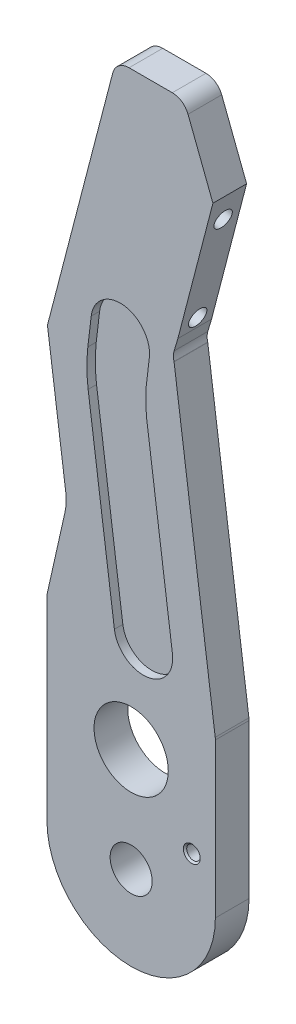
from build123d import *

# Parameters (mm, degrees)
SKETCH1_R                         = 7.9375
SKETCH1_R_2                       = 13.9954
BOSS_EXTRUDE1_DEPTH               = 12.7
FILLET3_R                         = 19.05
FILLET1_R                         = 6.35
F_10_CLEARANCE_HOLE2_D            = 5.1054
F_10_CLEARANCE_HOLE2_CSINK_D      = 6.3754
F_10_CLEARANCE_HOLE2_CSINK_ANGLE  = 90
CUT_EXTRUDE1_DEPTH                = 1
CUT_EXTRUDE1_DEPTH_BACK           = 13.7
FILLET2_R                         = 6.35
CUT_EXTRUDE3_DEPTH                = 1
CUT_EXTRUDE3_DEPTH_BACK           = 13.7
F_1_4_CLEARANCE_HOLE1_D           = 6.7564
F_1_4_CLEARANCE_HOLE1_CSINK_D     = 8.0264
F_1_4_CLEARANCE_HOLE1_CSINK_ANGLE = 90
CUT_EXTRUDE4_DEPTH                = 3.175
CUT_EXTRUDE5_DEPTH                = 3.175


with BuildPart() as part:
    # Sketch1 → Boss-Extrude1 (new body)
    with BuildSketch(Plane.XY):
        with BuildLine():
            Line((-24.200430201, 107.448474159), (-31.75, 73.770562428))
            Line((-31.75, 73.770562428), (-31.75, 0))
            ThreePointArc((-31.75, 0), (0, -31.75), (31.75, 0))
            Line((31.75, 0), (31.75, 116.627004246))
            Line((31.75, 116.627004246), (15.676297005, 175.624413942))
            Line((15.676297005, 175.624413942), (31.947601555, 229.990483385))
            Line((31.947601555, 229.990483385), (19.875208624, 261.32607122))
            Line((19.875208624, 261.32607122), (-5.524791376, 261.32607122))
            Line((-5.524791376, 261.32607122), (-32.716068836, 170.47392878))
            Line((-32.716068836, 170.47392878), (-24.200430201, 107.448474159))
        make_face()
        Circle(SKETCH1_R, mode=Mode.SUBTRACT)
        with Locations((0, 39.116)):
            Circle(SKETCH1_R_2, mode=Mode.SUBTRACT)
    extrude(amount=BOSS_EXTRUDE1_DEPTH)

    # Fillet3
    fillet3_edges = [part.edges().sort_by_distance(p)[0] for p in [
        (-24.200430201, 107.448474159, 6.35),
    ]]
    fillet(fillet3_edges, radius=FILLET3_R)

    # Fillet1
    fillet1_edges = [part.edges().sort_by_distance(p)[0] for p in [
        (-32.716068836, 170.47392878, 6.35),
        (-5.524791376, 261.32607122, 6.35),
        (19.875208624, 261.32607122, 6.35),
        (31.947601555, 229.990483385, 6.35),
        (15.676297005, 175.624413942, 6.35),
        (31.75, 116.627004246, 6.35),
        (-31.75, 73.770562428, 6.35),
    ]]
    fillet(fillet1_edges, radius=FILLET1_R)

    # #10 Clearance Hole2 (through all)
    with Locations(Plane.XY.offset(12.7)):
        with Locations((22.86, 16.52905)):
            CounterSinkHole(F_10_CLEARANCE_HOLE2_D / 2, F_10_CLEARANCE_HOLE2_CSINK_D / 2, counter_sink_angle=F_10_CLEARANCE_HOLE2_CSINK_ANGLE)

    # Sketch17 → Cut-Extrude1 (cut, two sides)
    with BuildSketch(Plane(origin=(0, 0, 0), x_dir=(-1, 0, 0), z_dir=(0, 0, -1))) as cut_extrude1_sk:
        with BuildLine():
            Line((-31.75, 58.539367012), (-16.179878819, 173.776051895))
            Line((-16.179878819, 173.776051895), (-31.526685006, 117.446666412))
            ThreePointArc((-31.526685006, 117.446666412), (-31.693923649, 116.619502039), (-31.75, 115.777465753))
            Line((-31.75, 115.777465753), (-31.75, 58.539367012))
        make_face()
    extrude(amount=CUT_EXTRUDE1_DEPTH, mode=Mode.SUBTRACT)
    extrude(cut_extrude1_sk.sketch, amount=-CUT_EXTRUDE1_DEPTH_BACK, mode=Mode.SUBTRACT)

    # Fillet2
    fillet2_edges = [part.edges().sort_by_distance(p)[0] for p in [
        (31.75, 58.539367012, 6.35),
    ]]
    fillet(fillet2_edges, radius=FILLET2_R)

    # Sketch19 → Cut-Extrude3 (cut, two sides)
    with BuildSketch(Plane(origin=(0, 0, 0), x_dir=(-1, 0, 0), z_dir=(0, 0, -1))) as cut_extrude3_sk:
        with BuildLine():
            Line((-17.620933209, 182.121878639), (-30.825593631, 232.902812203))
            Line((-30.825593631, 232.902812203), (-31.167525601, 232.015279853))
            ThreePointArc((-31.167525601, 232.015279853), (-31.587367542, 229.976620184), (-31.325446349, 227.911723628))
            Line((-31.325446349, 227.911723628), (-17.620933209, 182.121878639))
        make_face()
        with BuildLine():
            Line((32.32313572, 171.786806246), (6.880371133, 256.796775922))
            Line((6.880371133, 256.796775922), (31.557248698, 161.897335866))
            Line((31.557248698, 161.897335866), (32.532573251, 169.115851816))
            ThreePointArc((32.532573251, 169.115851816), (32.570321666, 170.462500309), (32.32313572, 171.786806246))
        make_face()
    extrude(amount=CUT_EXTRUDE3_DEPTH, mode=Mode.SUBTRACT)
    extrude(cut_extrude3_sk.sketch, amount=-CUT_EXTRUDE3_DEPTH_BACK, mode=Mode.SUBTRACT)

    # 1/4 Clearance Hole1 (through all)
    with Locations(Plane(origin=(-68.990792956, 17.939803964, 0), x_dir=(0, 0, 1), z_dir=(-0.967814998, 0.251662731, 0))):
        with Locations((6.35, 185.089358388), (6.35, 223.189358388)):
            CounterSinkHole(F_1_4_CLEARANCE_HOLE1_D / 2, F_1_4_CLEARANCE_HOLE1_CSINK_D / 2, counter_sink_angle=F_1_4_CLEARANCE_HOLE1_CSINK_ANGLE)

    # Sketch22 → Cut-Extrude4 (cut)
    with BuildSketch(Plane(origin=(0, 0, 0), x_dir=(-1, 0, 0), z_dir=(0, 0, -1))):
        with BuildLine():
            Line((-5.721549742, 151.036596427), (-15.563924684, 78.191777395))
            ThreePointArc((-15.563924684, 78.191777395), (-6.101580096, 65.772977875), (6.317219423, 75.235322463))
            Line((6.317219423, 75.235322463), (16.227356213, 148.58165658))
            ThreePointArc((16.227356213, 148.58165658), (16.127581623, 152.147558265), (14.895920611, 155.495486123))
            ThreePointArc((14.895920611, 155.495486123), (5.286667697, 150.045412833), (-4.233623122, 155.649438455))
            ThreePointArc((-4.233623122, 155.649438455), (-5.148189302, 153.664409279), (-5.653787894, 151.538111511))
            Line((-5.653787894, 151.538111511), (-5.721549742, 151.036596427))
        make_face()
        with BuildLine():
            ThreePointArc((14.895920611, 155.495486123), (5.375629793, 161.099511745), (-4.233623122, 155.649438455))
            ThreePointArc((-4.233623122, 155.649438455), (5.286667697, 150.045412833), (14.895920611, 155.495486123))
        make_face()
        with BuildLine():
            Line((-6.858366152, 170.484855738), (-5.647114594, 160.285630757))
            Line((-5.647114594, 160.285630757), (-5.587433271, 159.783090025))
            ThreePointArc((-5.587433271, 159.783090025), (-5.116122344, 157.648930204), (-4.233623122, 155.649438455))
            ThreePointArc((-4.233623122, 155.649438455), (5.375629793, 161.099511745), (14.895920611, 155.495486123))
            ThreePointArc((14.895920611, 155.495486123), (16.181306062, 158.823157086), (16.338459931, 162.386991041))
            Line((16.338459931, 162.386991041), (15.06752705, 173.088756754))
            ThreePointArc((15.06752705, 173.088756754), (2.802629941, 182.749752847), (-6.858366152, 170.484855738))
        make_face()
        with BuildLine():
            ThreePointArc((14.895920611, 155.495486123), (16.127581623, 152.147558265), (16.227356213, 148.58165658))
            ThreePointArc((16.227356213, 148.58165658), (16.719229878, 155.480812344), (16.338459931, 162.386991041))
            ThreePointArc((16.338459931, 162.386991041), (16.181306062, 158.823157086), (14.895920611, 155.495486123))
        make_face()
        with BuildLine():
            ThreePointArc((-5.647114594, 160.285630757), (-5.608314081, 155.660501807), (-5.721549742, 151.036596427))
            Line((-5.721549742, 151.036596427), (-5.653787894, 151.538111511))
            ThreePointArc((-5.653787894, 151.538111511), (-5.148189302, 153.664409279), (-4.233623122, 155.649438455))
            ThreePointArc((-4.233623122, 155.649438455), (-5.116122344, 157.648930204), (-5.587433271, 159.783090025))
            Line((-5.587433271, 159.783090025), (-5.647114594, 160.285630757))
        make_face()
    extrude(amount=-CUT_EXTRUDE4_DEPTH, mode=Mode.SUBTRACT)

    # Sketch23 → Cut-Extrude5 (cut)
    with BuildSketch(Plane.XY.offset(12.7)):
        with BuildLine():
            ThreePointArc((-6.317219423, 75.235322463), (6.101580096, 65.772977875), (15.563924684, 78.191777395))
            Line((15.563924684, 78.191777395), (5.721549742, 151.036596427))
            Line((5.721549742, 151.036596427), (5.653787894, 151.538111511))
            ThreePointArc((5.653787894, 151.538111511), (5.148189302, 153.664409279), (4.233623122, 155.649438455))
            ThreePointArc((4.233623122, 155.649438455), (-5.286667697, 150.045412833), (-14.895920611, 155.495486123))
            ThreePointArc((-14.895920611, 155.495486123), (-16.127581623, 152.147558265), (-16.227356213, 148.58165658))
            Line((-16.227356213, 148.58165658), (-6.317219423, 75.235322463))
        make_face()
        with BuildLine():
            ThreePointArc((-14.895920611, 155.495486123), (-5.286667697, 150.045412833), (4.233623122, 155.649438455))
            ThreePointArc((4.233623122, 155.649438455), (-5.375629793, 161.099511745), (-14.895920611, 155.495486123))
        make_face()
        with BuildLine():
            Line((5.587433271, 159.783090025), (5.647114594, 160.285630757))
            Line((5.647114594, 160.285630757), (6.858366152, 170.484855738))
            ThreePointArc((6.858366152, 170.484855738), (-2.802629941, 182.749752847), (-15.06752705, 173.088756754))
            Line((-15.06752705, 173.088756754), (-16.338459931, 162.386991041))
            ThreePointArc((-16.338459931, 162.386991041), (-16.181306062, 158.823157086), (-14.895920611, 155.495486123))
            ThreePointArc((-14.895920611, 155.495486123), (-5.375629793, 161.099511745), (4.233623122, 155.649438455))
            ThreePointArc((4.233623122, 155.649438455), (5.116122344, 157.648930204), (5.587433271, 159.783090025))
        make_face()
        with BuildLine():
            ThreePointArc((-16.338459931, 162.386991041), (-16.719229878, 155.480812344), (-16.227356213, 148.58165658))
            ThreePointArc((-16.227356213, 148.58165658), (-16.127581623, 152.147558265), (-14.895920611, 155.495486123))
            ThreePointArc((-14.895920611, 155.495486123), (-16.181306062, 158.823157086), (-16.338459931, 162.386991041))
        make_face()
        with BuildLine():
            Line((5.653787894, 151.538111511), (5.721549742, 151.036596427))
            ThreePointArc((5.721549742, 151.036596427), (5.608314081, 155.660501807), (5.647114594, 160.285630757))
            Line((5.647114594, 160.285630757), (5.587433271, 159.783090025))
            ThreePointArc((5.587433271, 159.783090025), (5.116122344, 157.648930204), (4.233623122, 155.649438455))
            ThreePointArc((4.233623122, 155.649438455), (5.148189302, 153.664409279), (5.653787894, 151.538111511))
        make_face()
    extrude(amount=-CUT_EXTRUDE5_DEPTH, mode=Mode.SUBTRACT)


solid = part.part
